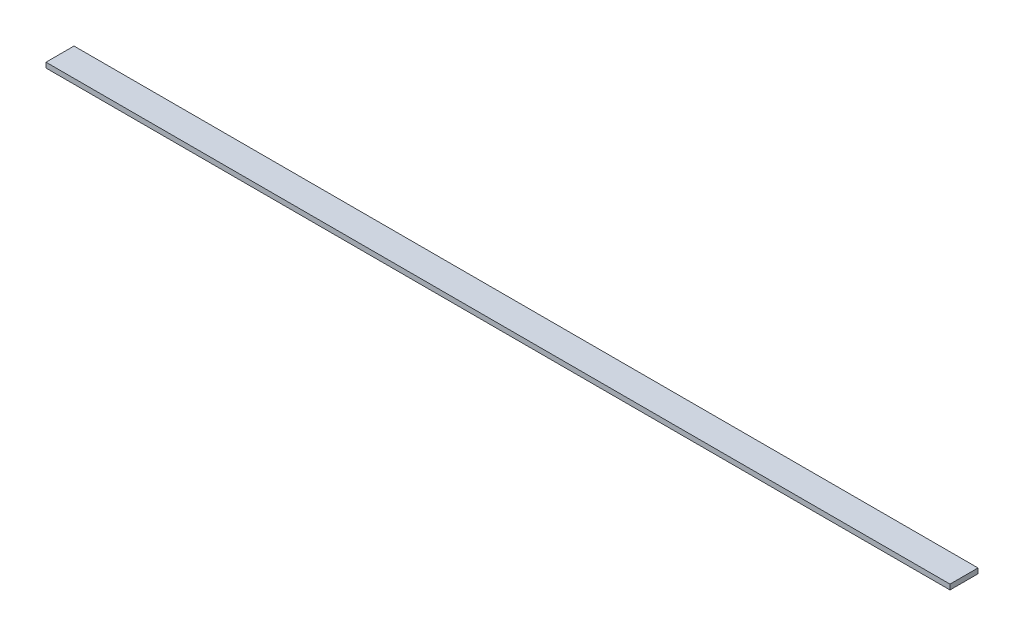
from build123d import *

# Parameters (mm, degrees)
SKETCH1_W           = 4508.5
SKETCH1_H           = 139.7
BOSS_EXTRUDE1_DEPTH = 25.4


with BuildPart() as part:
    # Sketch1 → Boss-Extrude1 (new body)
    with BuildSketch(Plane(origin=(0, 0, 0), x_dir=(1, 0, 0), z_dir=(0, 1, 0))):
        with Locations((2254.25, 69.85)):
            Rectangle(SKETCH1_W, SKETCH1_H)
    extrude(amount=BOSS_EXTRUDE1_DEPTH)


solid = part.part
